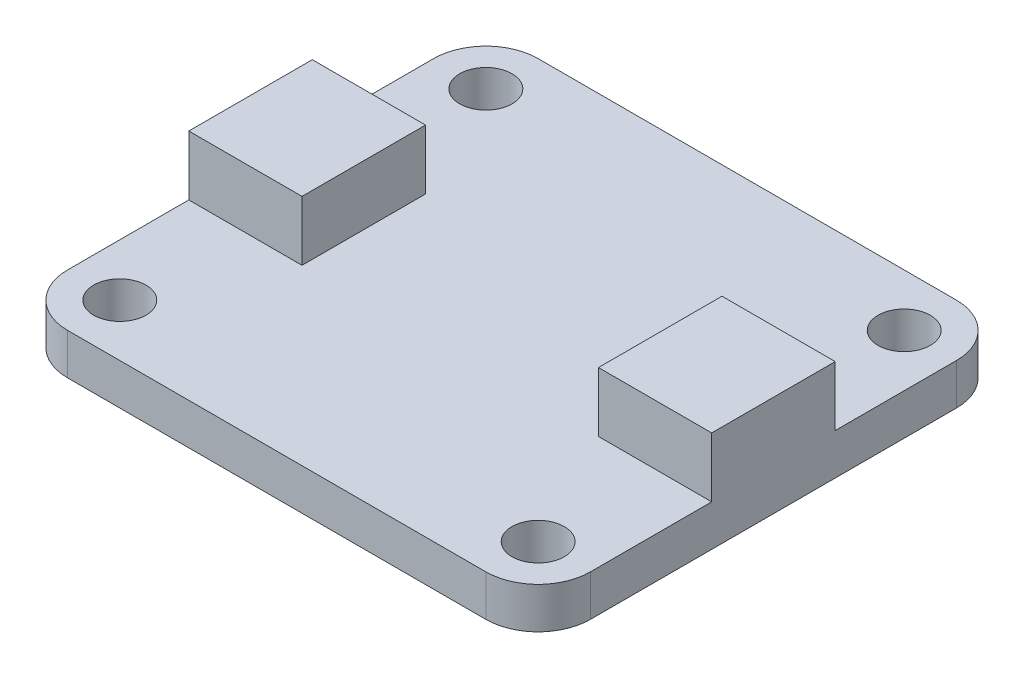
from build123d import *

# Parameters (mm, degrees)
SKETCH2_W           = 25.4
SKETCH2_H           = 22.86
BOSS_EXTRUDE1_DEPTH = 2
SKETCH5_R           = 1.27
CUT_EXTRUDE1_DEPTH  = 3
FILLET1_R           = 2.54
SKETCH6_W           = 5.5
SKETCH6_H           = 6
BOSS_EXTRUDE2_DEPTH = 2.9


with BuildPart() as part:
    # Sketch2 → Boss-Extrude1 (new body)
    with BuildSketch(Plane(origin=(0, 0, 0), x_dir=(1, 0, 0), z_dir=(0, 1, 0))):
        with Locations((12.7, 11.43)):
            Rectangle(SKETCH2_W, SKETCH2_H)
    extrude(amount=BOSS_EXTRUDE1_DEPTH)

    # Sketch5 → Cut-Extrude1 (cut, through all)
    with BuildSketch(Plane(origin=(0, 2, 0), x_dir=(1, 0, 0), z_dir=(0, 1, 0))):
        with Locations((2.54, 2.54)):
            Circle(SKETCH5_R)
        with Locations((22.86, 2.54)):
            Circle(SKETCH5_R)
        with Locations((22.86, 20.32)):
            Circle(SKETCH5_R)
        with Locations((2.54, 20.32)):
            Circle(SKETCH5_R)
    extrude(amount=-CUT_EXTRUDE1_DEPTH, mode=Mode.SUBTRACT)

    # Fillet1
    fillet1_edges = [part.edges().sort_by_distance(p)[0] for p in [
        (0, 1, -22.86),
        (25.4, 1, -22.86),
        (25.4, 1, 0),
        (0, 1, 0),
    ]]
    fillet(fillet1_edges, radius=FILLET1_R)

    # Sketch6 → Boss-Extrude2 (add)
    with BuildSketch(Plane(origin=(0, 2, 0), x_dir=(1, 0, 0), z_dir=(0, 1, 0))):
        with Locations((2.75, 11.43)):
            Rectangle(SKETCH6_W, SKETCH6_H)
        with Locations((22.65, 11.43)):
            Rectangle(SKETCH6_W, SKETCH6_H)
    extrude(amount=BOSS_EXTRUDE2_DEPTH)


solid = part.part
